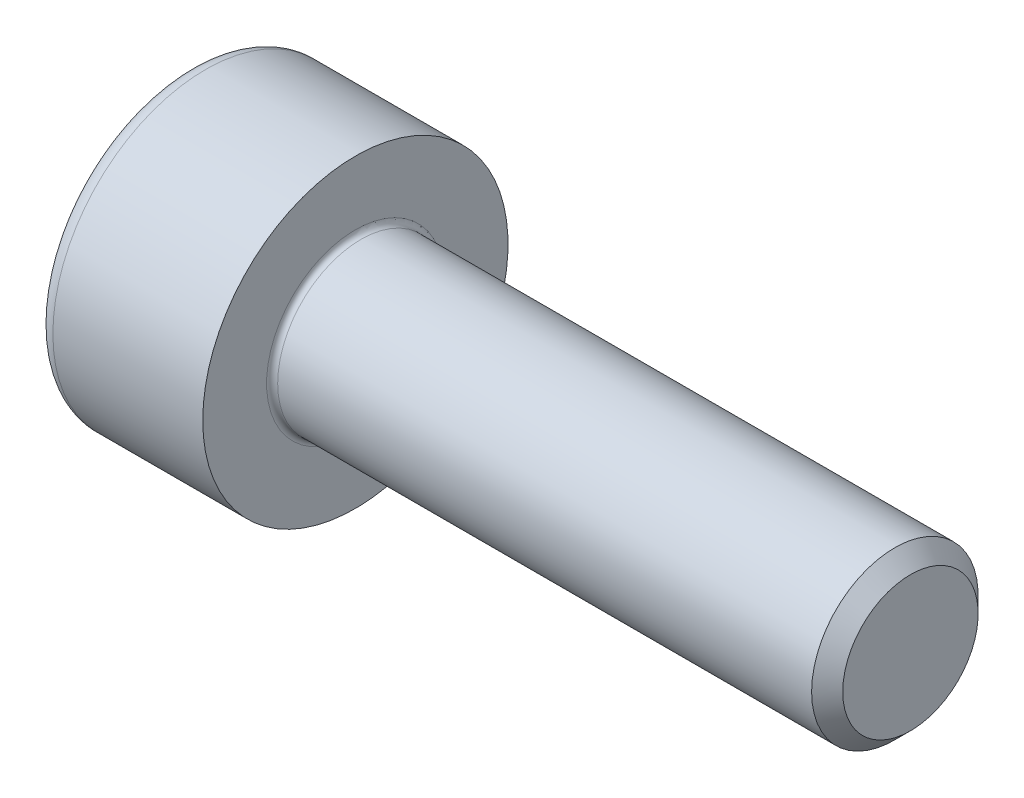
from build123d import *

# Parameters (mm, degrees)
FILLET1_R   = 0.1
FILLET2_R   = 0.3
HEX_2_DEPTH = 1.3


with BuildPart() as part:
    # BodySke → Base-Revolve (revolve)
    with BuildSketch(Plane.XY):
        Polygon((0, 0), (0, 2.75), (3, 2.75), (3, 1.5), (12.7195, 1.5), (13, 1.2195), (13, 0), align=None)
    revolve(axis=Axis((-31.75, 0, 0), (1, 0, 0)))

    # Fillet1
    fillet1_edges = [part.edges().sort_by_distance(p)[0] for p in [
        (3, -1.5, 0),
    ]]
    fillet(fillet1_edges, radius=FILLET1_R)

    # Fillet2
    fillet2_edges = [part.edges().sort_by_distance(p)[0] for p in [
        (0, -2.75, 0),
    ]]
    fillet(fillet2_edges, radius=FILLET2_R)

    # Sketch2 → Hex-PreBroach (revolve, cut)
    with BuildSketch(Plane.XY):
        Polygon((0, 1.26), (1.3, 1.26), (2.027461339, 0), (0, 0), align=None)
    revolve(axis=Axis((0, 0, 0), (1, 0, 0)), mode=Mode.SUBTRACT)

    # Sketch3 → Hex 2 (cut)
    with BuildSketch(Plane(origin=(0, 0, 0), x_dir=(0, 0.5, 0.866025404), z_dir=(-1, 0, 0))):
        Polygon((0.727461339, 1.26), (-0.727461339, 1.26), (-1.454922678, 0), (-0.727461339, -1.26), (0.727461339, -1.26), (1.454922678, 0), align=None)
    extrude(amount=-HEX_2_DEPTH, mode=Mode.SUBTRACT)


solid = part.part
